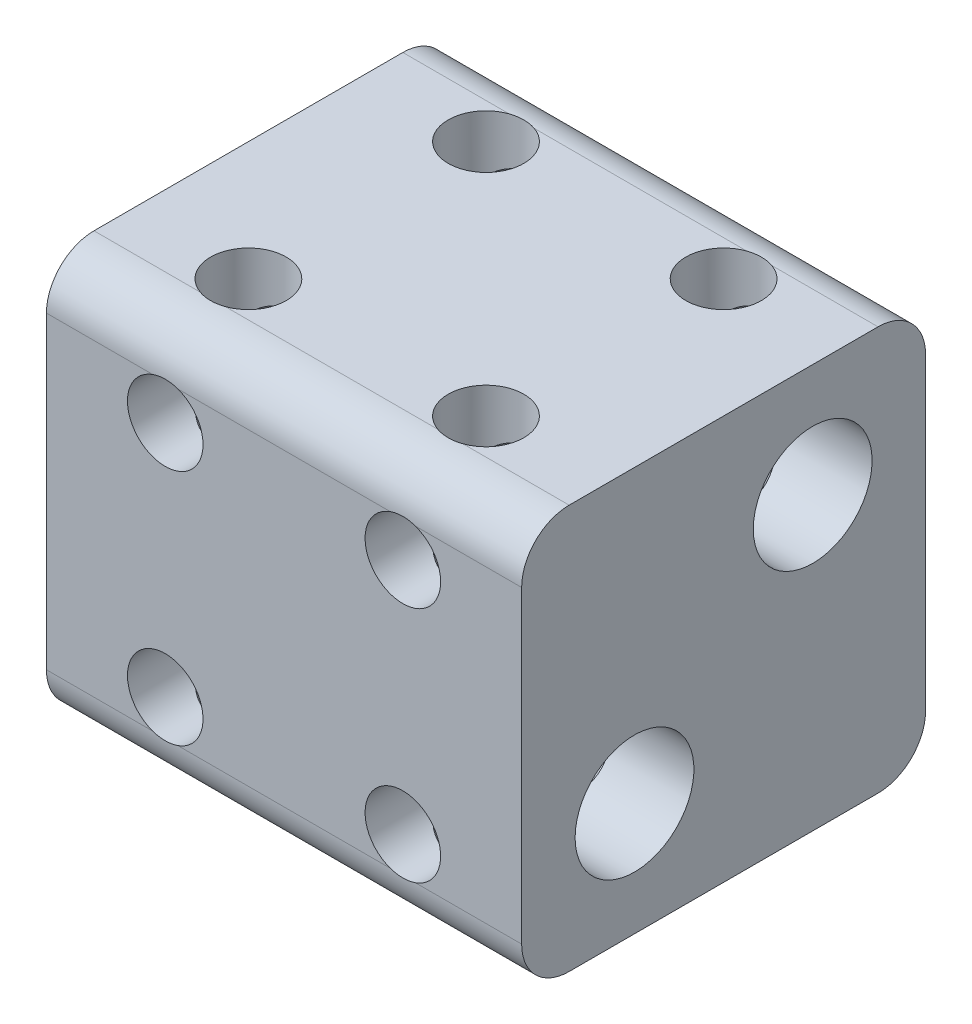
from build123d import *

# Parameters (mm, degrees)
BOSS_EXTRUDE1_DEPTH        = 25.4
F_1_4_0_2500_DOWEL_HOLE1_D = 6.35
F_10_32_TAPPED_HOLE2_D     = 4.0386


with BuildPart() as part:
    # Sketch1 → Boss-Extrude1 (new body)
    with BuildSketch(Plane(origin=(0, 0, 0), x_dir=(0, 0, -1), z_dir=(1, 0, 0))):
        with BuildLine():
            Line((8.255, -10.795), (-8.255, -10.795))
            ThreePointArc((-8.255, -10.795), (-10.051051224, -10.051051224), (-10.795, -8.255))
            Line((-10.795, -8.255), (-10.795, 8.255))
            ThreePointArc((-10.795, 8.255), (-10.051051224, 10.051051224), (-8.255, 10.795))
            Line((-8.255, 10.795), (8.255, 10.795))
            ThreePointArc((8.255, 10.795), (10.051051224, 10.051051224), (10.795, 8.255))
            Line((10.795, 8.255), (10.795, -8.255))
            ThreePointArc((10.795, -8.255), (10.051051224, -10.051051224), (8.255, -10.795))
        make_face()
    extrude(amount=BOSS_EXTRUDE1_DEPTH)

    # 1/4 (0.2500) Dowel Hole1 (through all)
    with Locations(Plane.ZY):
        with Locations((-4.7625, 4.7625), (4.7625, -4.7625)):
            Hole(F_1_4_0_2500_DOWEL_HOLE1_D / 2)

    # #10-32 Tapped Hole2 (through all)
    with Locations(Plane.XY.offset(10.795)):
        with Locations((6.35, 6.35), (19.05, 6.35), (6.35, -6.35), (19.05, -6.35)):
            f_10_32_tapped_hole2 = Hole(F_10_32_TAPPED_HOLE2_D / 2)

    # Mirror1: #10-32 Tapped Hole2 across plane
    add(f_10_32_tapped_hole2.mirror(Plane(origin=(0, 0, 0), x_dir=(0, 0.707106781, 0.707106781), z_dir=(0, -0.707106781, 0.707106781))), mode=Mode.SUBTRACT)


solid = part.part
